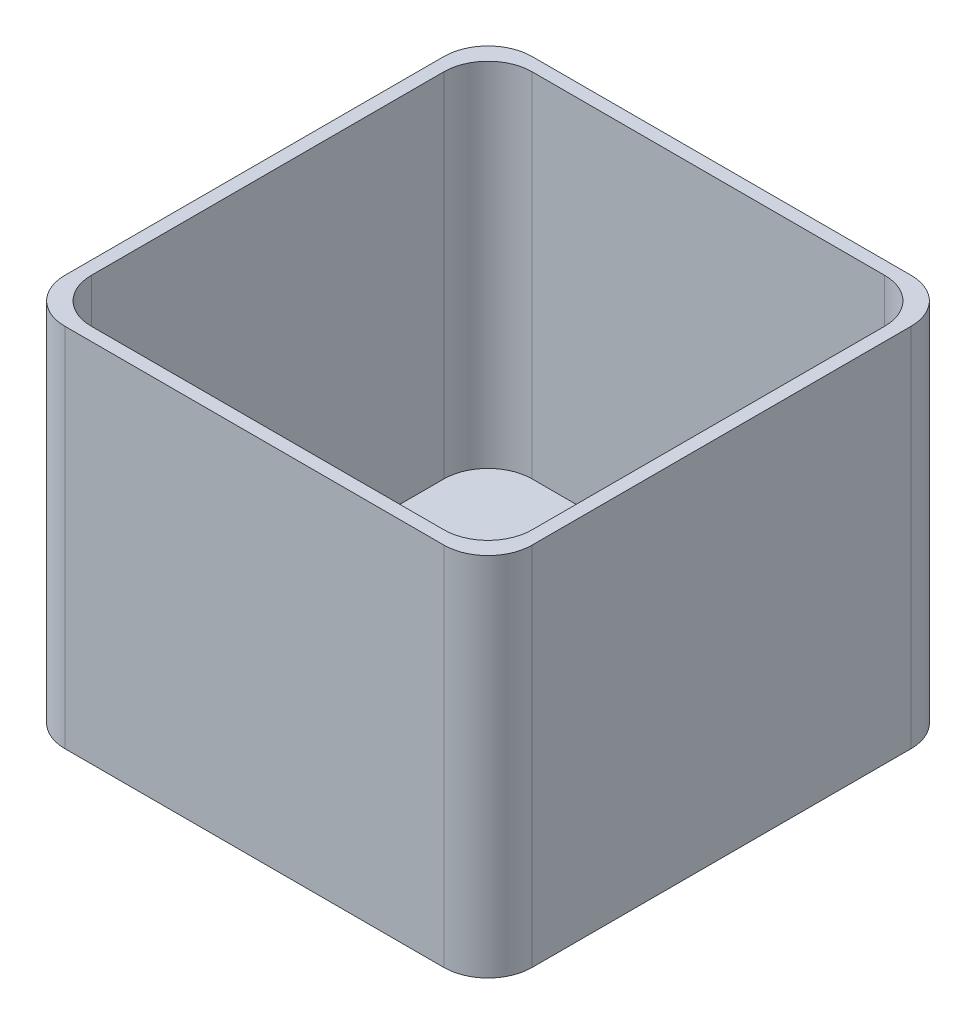
from build123d import *

# Parameters (mm, degrees)
BOSS_EXTRUDE1_DEPTH = 80
SKETCH2_R           = 4.778019897
BOSS_EXTRUDE4_DEPTH = 3


with BuildPart() as part:
    # Sketch1 → Boss-Extrude1 (new body)
    with BuildSketch(Plane(origin=(0, 0, 0), x_dir=(1, 0, 0), z_dir=(0, 1, 0))):
        with BuildLine():
            ThreePointArc((-83.878172589, 11.35786802), (-80.949240401, 18.428935832), (-73.878172589, 21.35786802))
            Line((-73.878172589, 21.35786802), (12.121827411, 21.35786802))
            ThreePointArc((12.121827411, 21.35786802), (19.192895223, 18.428935832), (22.121827411, 11.35786802))
            Line((22.121827411, 11.35786802), (22.121827411, -74.64213198))
            ThreePointArc((22.121827411, -74.64213198), (19.192895223, -81.713199792), (12.121827411, -84.64213198))
            Line((12.121827411, -84.64213198), (-73.878172589, -84.64213198))
            ThreePointArc((-73.878172589, -84.64213198), (-80.949240401, -81.713199792), (-83.878172589, -74.64213198))
            Line((-83.878172589, -74.64213198), (-83.878172589, 11.35786802))
        make_face()
        with BuildLine():
            Line((-70.878172589, 18.35786802), (9.121827411, 18.35786802))
            ThreePointArc((9.121827411, 18.35786802), (16.192895223, 15.428935832), (19.121827411, 8.35786802))
            Line((19.121827411, 8.35786802), (19.121827411, -71.64213198))
            ThreePointArc((19.121827411, -71.64213198), (16.192895223, -78.713199792), (9.121827411, -81.64213198))
            Line((9.121827411, -81.64213198), (-70.878172589, -81.64213198))
            ThreePointArc((-70.878172589, -81.64213198), (-77.949240401, -78.713199792), (-80.878172589, -71.64213198))
            Line((-80.878172589, -71.64213198), (-80.878172589, 8.35786802))
            ThreePointArc((-80.878172589, 8.35786802), (-77.949240401, 15.428935832), (-70.878172589, 18.35786802))
        make_face(mode=Mode.SUBTRACT)
    extrude(amount=BOSS_EXTRUDE1_DEPTH)

    # Sketch2 → Boss-Extrude4 (add)
    with BuildSketch(Plane.XZ):
        with BuildLine():
            Line((-83.878172589, 74.64213198), (-83.878172589, -11.35786802))
            ThreePointArc((-83.878172589, -11.35786802), (-80.949240401, -18.428935832), (-73.878172589, -21.35786802))
            Line((-73.878172589, -21.35786802), (12.121827411, -21.35786802))
            ThreePointArc((12.121827411, -21.35786802), (19.192895223, -18.428935832), (22.121827411, -11.35786802))
            Line((22.121827411, -11.35786802), (22.121827411, 74.64213198))
            ThreePointArc((22.121827411, 74.64213198), (19.192895223, 81.713199792), (12.121827411, 84.64213198))
            Line((12.121827411, 84.64213198), (-73.878172589, 84.64213198))
            ThreePointArc((-73.878172589, 84.64213198), (-80.949240401, 81.713199792), (-83.878172589, 74.64213198))
        make_face()
        with BuildLine():
            ThreePointArc((19.121827411, -8.35786802), (16.192895223, -15.428935832), (9.121827411, -18.35786802))
            Line((9.121827411, -18.35786802), (-70.878172589, -18.35786802))
            ThreePointArc((-70.878172589, -18.35786802), (-77.949240401, -15.428935832), (-80.878172589, -8.35786802))
            Line((-80.878172589, -8.35786802), (-80.878172589, 71.64213198))
            ThreePointArc((-80.878172589, 71.64213198), (-77.949240401, 78.713199792), (-70.878172589, 81.64213198))
            Line((-70.878172589, 81.64213198), (9.121827411, 81.64213198))
            ThreePointArc((9.121827411, 81.64213198), (16.192895223, 78.713199792), (19.121827411, 71.64213198))
            Line((19.121827411, 71.64213198), (19.121827411, -8.35786802))
        make_face(mode=Mode.SUBTRACT)
        with BuildLine():
            Line((9.121827411, -18.35786802), (-70.878172589, -18.35786802))
            ThreePointArc((-70.878172589, -18.35786802), (-77.949240401, -15.428935832), (-80.878172589, -8.35786802))
            Line((-80.878172589, -8.35786802), (-80.878172589, 71.64213198))
            ThreePointArc((-80.878172589, 71.64213198), (-77.949240401, 78.713199792), (-70.878172589, 81.64213198))
            Line((-70.878172589, 81.64213198), (9.121827411, 81.64213198))
            ThreePointArc((9.121827411, 81.64213198), (16.192895223, 78.713199792), (19.121827411, 71.64213198))
            Line((19.121827411, 71.64213198), (19.121827411, -8.35786802))
            ThreePointArc((19.121827411, -8.35786802), (16.192895223, -15.428935832), (9.121827411, -18.35786802))
        make_face()
        with Locations(Location((13.968668107, -4.778019897, 0), (0, 0, 270))):
            Circle(SKETCH2_R, mode=Mode.SUBTRACT)
    extrude(amount=BOSS_EXTRUDE4_DEPTH)


solid = part.part
